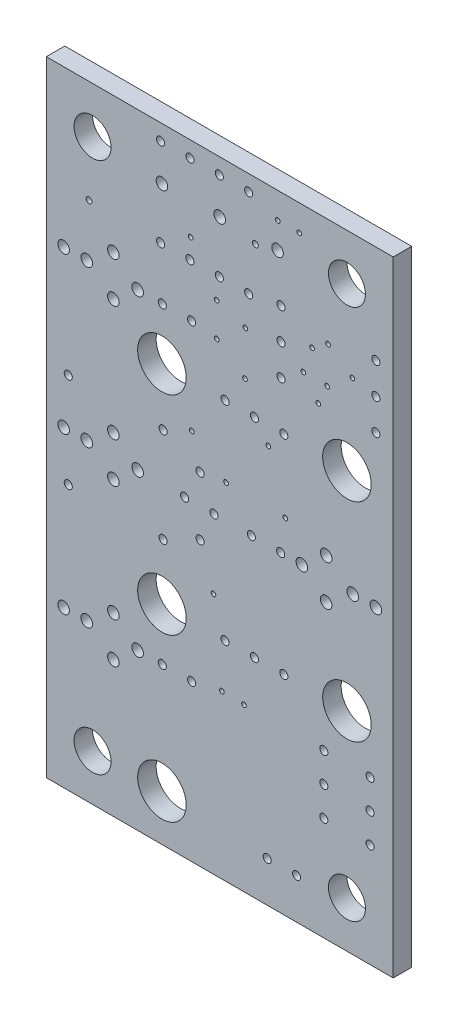
from build123d import *

# Parameters (mm, degrees)
MODEL_W            = 30
MODEL_H            = 54
MODEL_R            = 2.1
MODEL_R_2          = 0.35
MODEL_R_3          = 0.2
MODEL_R_4          = 0.5
MODEL_R_5          = 0.25
MODEL_R_6          = 0.254
MODEL_R_7          = 1.6
BOSS_EXTRU_1_DEPTH = 1.6


with BuildPart() as part:
    # Model → Boss.-Extru.1 (new body)
    with BuildSketch(Plane.XY):
        with Locations((15, 27)):
            Rectangle(MODEL_W, MODEL_H)
        with Locations((9.99998, 4.0005)):
            Circle(MODEL_R, mode=Mode.SUBTRACT)
        with Locations((9.99998, 18.00098)):
            Circle(MODEL_R, mode=Mode.SUBTRACT)
        with Locations((25.99944, 18.00098)):
            Circle(MODEL_R, mode=Mode.SUBTRACT)
        with Locations((9.99998, 35.99942)):
            Circle(MODEL_R, mode=Mode.SUBTRACT)
        with Locations((25.99944, 35.99942)):
            Circle(MODEL_R, mode=Mode.SUBTRACT)
        with Locations((10.10031, 22.90064)):
            Circle(MODEL_R_2, mode=Mode.SUBTRACT)
        with Locations((19.2024, 34.44748)):
            Circle(MODEL_R_3, mode=Mode.SUBTRACT)
        with Locations((23.99919, 8.96112)):
            Circle(MODEL_R_2, mode=Mode.SUBTRACT)
        with Locations((28.00046, 14.04112)):
            Circle(MODEL_R_2, mode=Mode.SUBTRACT)
        with Locations((27.99919, 8.96112)):
            Circle(MODEL_R_2, mode=Mode.SUBTRACT)
        with Locations((7.8994, 27.0002)):
            Circle(MODEL_R_4, mode=Mode.SUBTRACT)
        with Locations((12.57046, 40.5003)):
            Circle(MODEL_R_2, mode=Mode.SUBTRACT)
        with Locations((21.64461, 3.50012)):
            Circle(MODEL_R_2, mode=Mode.SUBTRACT)
        with Locations((19.10461, 3.50012)):
            Circle(MODEL_R_2, mode=Mode.SUBTRACT)
        with Locations((17.99971, 18.00098)):
            Circle(MODEL_R_2, mode=Mode.SUBTRACT)
        with Locations((15.45971, 18.00098)):
            Circle(MODEL_R_2, mode=Mode.SUBTRACT)
        with Locations((26.50134, 27.0002)):
            Circle(MODEL_R_4, mode=Mode.SUBTRACT)
        with Locations((24.20112, 25.25026)):
            Circle(MODEL_R_4, mode=Mode.SUBTRACT)
        with Locations((20.27047, 27.0002)):
            Circle(MODEL_R_2, mode=Mode.SUBTRACT)
        with Locations((12.58316, 32.26816)):
            Circle(MODEL_R_3, mode=Mode.SUBTRACT)
        with Locations((10.02919, 13.5001)):
            Circle(MODEL_R_2, mode=Mode.SUBTRACT)
        with Locations((1.4986, 13.50137)):
            Circle(MODEL_R_4, mode=Mode.SUBTRACT)
        with Locations((3.4986, 13.50137)):
            Circle(MODEL_R_4, mode=Mode.SUBTRACT)
        with Locations((7.8986, 13.50137)):
            Circle(MODEL_R_4, mode=Mode.SUBTRACT)
        with Locations((5.7986, 11.75137)):
            Circle(MODEL_R_4, mode=Mode.SUBTRACT)
        with Locations((5.7986, 15.25137)):
            Circle(MODEL_R_4, mode=Mode.SUBTRACT)
        with Locations((10.10031, 31.09976)):
            Circle(MODEL_R_2, mode=Mode.SUBTRACT)
        with Locations((17.18564, 38.48354)):
            Circle(MODEL_R_3, mode=Mode.SUBTRACT)
        with Locations((1.89992, 22.89937)):
            Circle(MODEL_R_2, mode=Mode.SUBTRACT)
        with Locations((10.03046, 40.5003)):
            Circle(MODEL_R_2, mode=Mode.SUBTRACT)
        with Locations((1.89992, 31.09976)):
            Circle(MODEL_R_2, mode=Mode.SUBTRACT)
        with Locations((1.4994, 27.0002)):
            Circle(MODEL_R_4, mode=Mode.SUBTRACT)
        with Locations((3.4994, 27.0002)):
            Circle(MODEL_R_4, mode=Mode.SUBTRACT)
        with Locations((5.7994, 25.2502)):
            Circle(MODEL_R_4, mode=Mode.SUBTRACT)
        with Locations((5.7994, 28.7502)):
            Circle(MODEL_R_4, mode=Mode.SUBTRACT)
        with Locations((11.95959, 27.0002)):
            Circle(MODEL_R_2, mode=Mode.SUBTRACT)
        with Locations((14.49959, 27.0002)):
            Circle(MODEL_R_2, mode=Mode.SUBTRACT)
        with Locations((15.45971, 35.99942)):
            Circle(MODEL_R_2, mode=Mode.SUBTRACT)
        with Locations((28.50007, 42.79902)):
            Circle(MODEL_R_2, mode=Mode.SUBTRACT)
        with Locations((28.50007, 40.09902)):
            Circle(MODEL_R_2, mode=Mode.SUBTRACT)
        with Locations((12.42314, 45.00372)):
            Circle(MODEL_R_2, mode=Mode.SUBTRACT)
        with Locations((28.50007, 45.49902)):
            Circle(MODEL_R_2, mode=Mode.SUBTRACT)
        with Locations((14.96314, 45.00372)):
            Circle(MODEL_R_2, mode=Mode.SUBTRACT)
        with Locations((17.50314, 45.00372)):
            Circle(MODEL_R_2, mode=Mode.SUBTRACT)
        with Locations((14.96314, 52.62372)):
            Circle(MODEL_R_2, mode=Mode.SUBTRACT)
        with Locations((12.42314, 52.62372)):
            Circle(MODEL_R_2, mode=Mode.SUBTRACT)
        with Locations((9.88314, 52.62372)):
            Circle(MODEL_R_2, mode=Mode.SUBTRACT)
        with Locations((14.99998, 49.49952)):
            Circle(MODEL_R_4, mode=Mode.SUBTRACT)
        with Locations((24.36368, 44.65066)):
            Circle(MODEL_R_3, mode=Mode.SUBTRACT)
        with Locations((1.4986, 40.50157)):
            Circle(MODEL_R_4, mode=Mode.SUBTRACT)
        with Locations((28.50134, 27.0002)):
            Circle(MODEL_R_4, mode=Mode.SUBTRACT)
        with Locations((7.8986, 40.50157)):
            Circle(MODEL_R_4, mode=Mode.SUBTRACT)
        with Locations((3.4986, 40.50157)):
            Circle(MODEL_R_4, mode=Mode.SUBTRACT)
        with Locations((5.7986, 38.75157)):
            Circle(MODEL_R_4, mode=Mode.SUBTRACT)
        with Locations((5.7986, 42.25157)):
            Circle(MODEL_R_4, mode=Mode.SUBTRACT)
        with Locations((20.02448, 51.74742)):
            Circle(MODEL_R_3, mode=Mode.SUBTRACT)
        with Locations((13.29944, 24.4602)):
            Circle(MODEL_R_2, mode=Mode.SUBTRACT)
        with Locations((24.00046, 14.04112)):
            Circle(MODEL_R_2, mode=Mode.SUBTRACT)
        with Locations((20.30095, 45.49902)):
            Circle(MODEL_R_2, mode=Mode.SUBTRACT)
        with Locations((12.49045, 46.73346)):
            Circle(MODEL_R_3, mode=Mode.SUBTRACT)
        with Locations((3.69697, 45.0977)):
            Circle(MODEL_R_5, mode=Mode.SUBTRACT)
        with Locations((12.56919, 13.5001)):
            Circle(MODEL_R_2, mode=Mode.SUBTRACT)
        with Locations((17.21866, 42.3037)):
            Circle(MODEL_R_3, mode=Mode.SUBTRACT)
        with Locations((20.29968, 42.799)):
            Circle(MODEL_R_2, mode=Mode.SUBTRACT)
        with Locations((17.73047, 27.0002)):
            Circle(MODEL_R_2, mode=Mode.SUBTRACT)
        with Locations((15.54353, 29.8831)):
            Circle(MODEL_R_3, mode=Mode.SUBTRACT)
        with Locations((20.30095, 40.09898)):
            Circle(MODEL_R_2, mode=Mode.SUBTRACT)
        with Locations((27.99969, 11.50112)):
            Circle(MODEL_R_2, mode=Mode.SUBTRACT)
        with Locations((26.47315, 43.18)):
            Circle(MODEL_R_3, mode=Mode.SUBTRACT)
        with Locations((21.87448, 51.74742)):
            Circle(MODEL_R_3, mode=Mode.SUBTRACT)
        with Locations((17.50314, 52.62372)):
            Circle(MODEL_R_2, mode=Mode.SUBTRACT)
        with Locations((15.1892, 14.07668)):
            Circle(MODEL_R_3, mode=Mode.SUBTRACT)
        with Locations((14.45768, 21.00072)):
            Circle(MODEL_R_3, mode=Mode.SUBTRACT)
        with Locations((23.99919, 11.50112)):
            Circle(MODEL_R_2, mode=Mode.SUBTRACT)
        with Locations((17.09928, 14.01318)):
            Circle(MODEL_R_3, mode=Mode.SUBTRACT)
        with Locations((20.53971, 18.00098)):
            Circle(MODEL_R_2, mode=Mode.SUBTRACT)
        with Locations((23.52421, 39.80434)):
            Circle(MODEL_R_3, mode=Mode.SUBTRACT)
        with Locations((22.10181, 27.0002)):
            Circle(MODEL_R_4, mode=Mode.SUBTRACT)
        with Locations((18.08226, 48.99914)):
            Circle(MODEL_R_6, mode=Mode.SUBTRACT)
        with Locations((22.23262, 41.49598)):
            Circle(MODEL_R_3, mode=Mode.SUBTRACT)
        with Locations((14.73835, 40.2336)):
            Circle(MODEL_R_3, mode=Mode.SUBTRACT)
        with Locations((14.73835, 43.13174)):
            Circle(MODEL_R_3, mode=Mode.SUBTRACT)
        with Locations((9.99998, 49.49952)):
            Circle(MODEL_R_4, mode=Mode.SUBTRACT)
        with Locations((17.99971, 35.99942)):
            Circle(MODEL_R_2, mode=Mode.SUBTRACT)
        with Locations((9.88314, 45.00372)):
            Circle(MODEL_R_2, mode=Mode.SUBTRACT)
        with Locations((19.99996, 49.49952)):
            Circle(MODEL_R_4, mode=Mode.SUBTRACT)
        with Locations((24.2824, 41.46804)):
            Circle(MODEL_R_3, mode=Mode.SUBTRACT)
        with Locations((22.98192, 43.69054)):
            Circle(MODEL_R_3, mode=Mode.SUBTRACT)
        with Locations((20.67179, 29.78912)):
            Circle(MODEL_R_3, mode=Mode.SUBTRACT)
        with Locations((24.20112, 28.75026)):
            Circle(MODEL_R_4, mode=Mode.SUBTRACT)
        with Locations((13.29944, 29.5402)):
            Circle(MODEL_R_2, mode=Mode.SUBTRACT)
        with Locations((20.53971, 35.99942)):
            Circle(MODEL_R_2, mode=Mode.SUBTRACT)
        with Locations((4, 50)):
            Circle(MODEL_R_7, mode=Mode.SUBTRACT)
        with Locations(Location((26, 50, 0), (0, 0, 180))):  # turned: the seam where the file's is
            Circle(MODEL_R_7, mode=Mode.SUBTRACT)
        with Locations(Location((4, 4, 0), (0, 0, 180))):  # turned: the seam where the file's is
            Circle(MODEL_R_7, mode=Mode.SUBTRACT)
        with Locations((26, 4)):
            Circle(MODEL_R_7, mode=Mode.SUBTRACT)
    extrude(amount=BOSS_EXTRU_1_DEPTH)


solid = part.part
